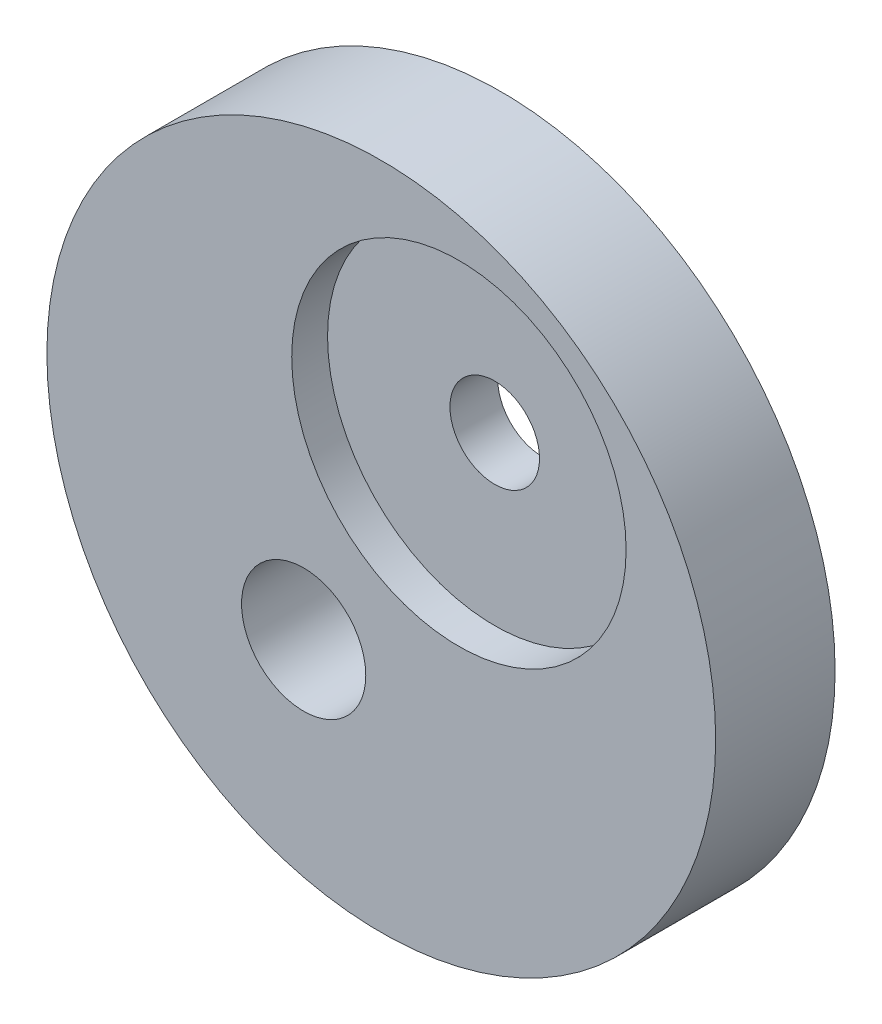
from build123d import *

# Parameters (mm, degrees)
ESQUISSE1_R             = 14
ESQUISSE1_R_2           = 1.874597255
ESQUISSE1_R_3           = 2.6
BOSS_EXTRU_1_DEPTH      = 5
ESQUISSE2_R             = 7
ENL_V_MAT_EXTRU_1_DEPTH = 1.5
ESQUISSE3_R             = 7
ENL_V_MAT_EXTRU_2_DEPTH = 1.5


with BuildPart() as part:
    # Esquisse1 → Boss.-Extru.1 (new body)
    with BuildSketch(Plane.XY):
        with Locations((-3.25, -5)):
            Circle(ESQUISSE1_R)
        Circle(ESQUISSE1_R_2, mode=Mode.SUBTRACT)
        with Locations((-6.5, -10)):
            Circle(ESQUISSE1_R_3, mode=Mode.SUBTRACT)
    extrude(amount=BOSS_EXTRU_1_DEPTH)

    # Esquisse2 → Enlèv. mat.-Extru.1 (cut)
    with BuildSketch(Plane.XY.offset(5)):
        Circle(ESQUISSE2_R)
    extrude(amount=-ENL_V_MAT_EXTRU_1_DEPTH, mode=Mode.SUBTRACT)

    # Esquisse3 → Enlèv. mat.-Extru.2 (cut)
    with BuildSketch(Plane(origin=(0, 0, 0), x_dir=(-1, 0, 0), z_dir=(0, 0, -1))):
        Circle(ESQUISSE3_R)
    extrude(amount=-ENL_V_MAT_EXTRU_2_DEPTH, mode=Mode.SUBTRACT)


solid = part.part
